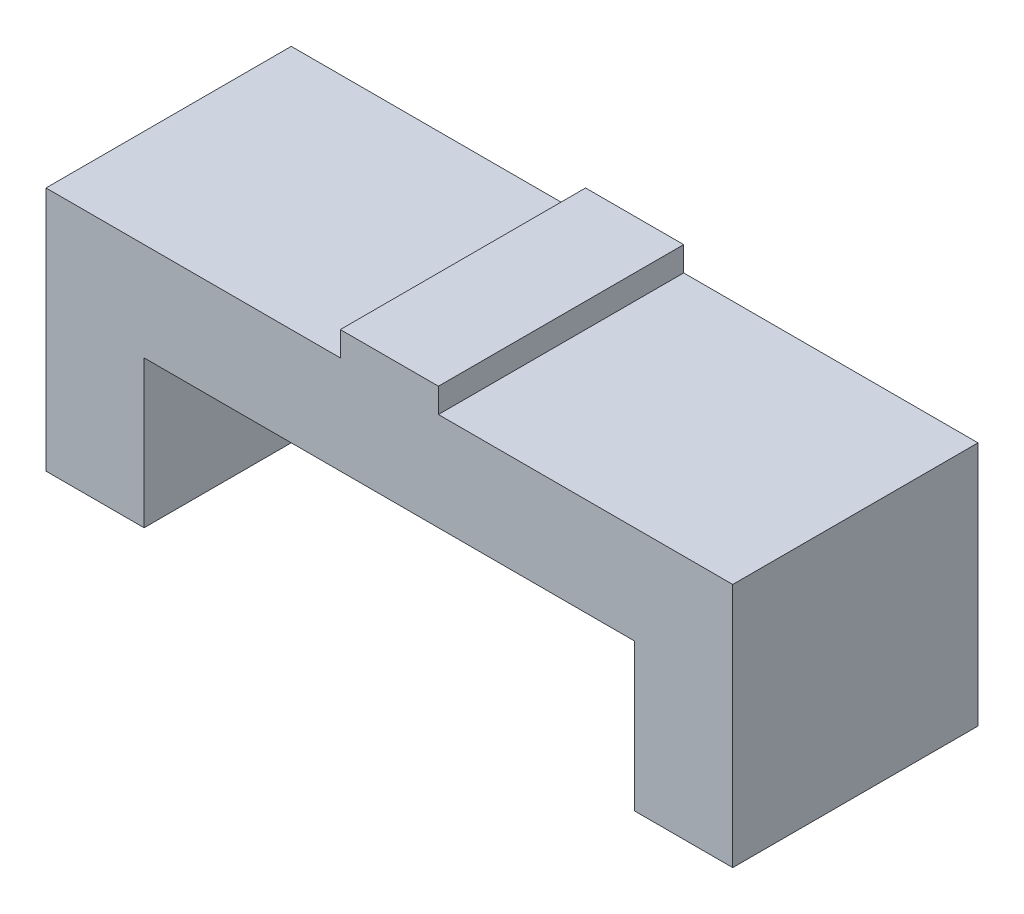
from build123d import *

# Parameters (mm, degrees)
BOSS_EXTRUDE1_DEPTH = 50
SKETCH2_W           = 20
SKETCH2_H           = 50
BOSS_EXTRUDE2_DEPTH = 5


with BuildPart() as part:
    # Sketch1 → Boss-Extrude1 (new body)
    with BuildSketch(Plane.XY):
        Polygon((-70, 0), (-50, 0), (-50, 30), (50, 30), (50, 0), (70, 0), (70, 50), (-70, 50), align=None)
    extrude(amount=BOSS_EXTRUDE1_DEPTH)

    # Sketch2 → Boss-Extrude2 (add)
    with BuildSketch(Plane(origin=(0, 50, 0), x_dir=(1, 0, 0), z_dir=(0, 1, 0))):
        with Locations((0, -25)):
            Rectangle(SKETCH2_W, SKETCH2_H)
    extrude(amount=BOSS_EXTRUDE2_DEPTH)


solid = part.part
